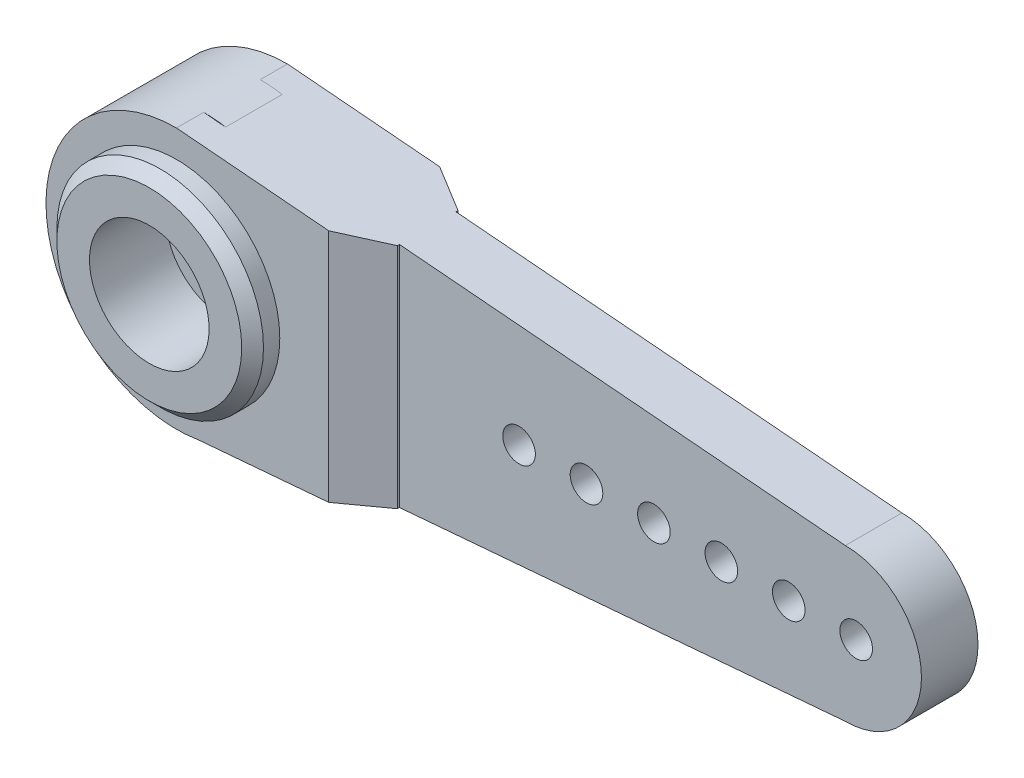
from build123d import *

# Parameters (mm, degrees)
BOSS_EXTRUDE1_DEPTH = 2.6
SKETCH2_R           = 4.75
BOSS_EXTRUDE2_DEPTH = 2.5
SKETCH3_R           = 2.5
CUT_EXTRUDE1_DEPTH  = 4
SKETCH4_R           = 0.75
CUT_EXTRUDE2_DEPTH  = 4
SKETCH5_R           = 4.75
BOSS_EXTRUDE3_DEPTH = 1.25
CHAMFER1_SIZE       = 2
CHAMFER1_SIZE2      = 1.154700538
BOSS_EXTRUDE4_DEPTH = 1.25
CHAMFER2_SIZE       = 2
CHAMFER2_SIZE2      = 1.154700538
SKETCH7_W           = 3
SKETCH7_H           = 5
CUT_EXTRUDE3_DEPTH  = 1.25
SKETCH8_R           = 2.75
CUT_EXTRUDE4_DEPTH  = 3.5
SKETCH9_R           = 3.4
CUT_EXTRUDE5_DEPTH  = 2
CHAMFER3_SIZE       = 0.5
SKETCH10_R          = 1.5
CUT_EXTRUDE6_DEPTH  = 5


with BuildPart() as part:
    # Sketch1 → Boss-Extrude1 (new body)
    with BuildSketch(Plane.XY):
        with BuildLine():
            Line((1.009697661, 5.914432402), (29.5, 3.5))
            ThreePointArc((29.5, 3.5), (33, 0), (29.5, -3.5))
            Line((29.5, -3.5), (1.009697661, -5.914432402))
            ThreePointArc((1.009697661, -5.914432402), (-6, 0), (1.009697661, 5.914432402))
        make_face()
    extrude(amount=BOSS_EXTRUDE1_DEPTH)

    # Sketch2 → Boss-Extrude2 (add)
    with BuildSketch(Plane.XY.offset(2.6)):
        Circle(SKETCH2_R)
    extrude(amount=BOSS_EXTRUDE2_DEPTH)

    # Sketch3 → Cut-Extrude1 (cut)
    with BuildSketch(Plane.XY.offset(2.6)):
        Circle(SKETCH3_R)
    extrude(amount=CUT_EXTRUDE1_DEPTH, mode=Mode.SUBTRACT)

    # Sketch4 → Cut-Extrude2 (cut)
    with BuildSketch(Plane.XY.offset(2.6)):
        with Locations((30, 0)):
            Circle(SKETCH4_R)
        with Locations((26.9, 0)):
            Circle(SKETCH4_R)
        with Locations((23.8, 0)):
            Circle(SKETCH4_R)
        with Locations((20.7, 0)):
            Circle(SKETCH4_R)
        with Locations((17.6, 0)):
            Circle(SKETCH4_R)
        with Locations((14.5, 0)):
            Circle(SKETCH4_R)
    extrude(amount=-CUT_EXTRUDE2_DEPTH, mode=Mode.SUBTRACT)

    # Sketch5 → Boss-Extrude3 (add)
    with BuildSketch(Plane.XY.offset(2.6)):
        with BuildLine():
            Line((1.009697661, 5.914432402), (0, 6))
            ThreePointArc((0, 6), (-5.978569829, -0.50665846), (1.009697661, -5.914432402))
            Line((1.009697661, -5.914432402), (9, -5.237288136))
            Line((9, -5.237288136), (9, 5.237288136))
            Line((9, 5.237288136), (1.009697661, 5.914432402))
        make_face()
        Circle(SKETCH5_R, mode=Mode.SUBTRACT)
    extrude(amount=BOSS_EXTRUDE3_DEPTH)

    # Chamfer1
    chamfer1_edges = [part.edges().sort_by_distance(p)[0] for p in [
        (9, 0, 3.85),
    ]]
    chamfer1_side = [part.faces().sort_by_distance(p)[0] for p in [
        (4.988627845, -5.384452642, 3.85),
    ]]
    chamfer(chamfer1_edges, length=CHAMFER1_SIZE, length2=CHAMFER1_SIZE2, reference=chamfer1_side[0])

    # Sketch6 → Boss-Extrude4 (add)
    with BuildSketch(Plane(origin=(0, 0, 0), x_dir=(-1, 0, 0), z_dir=(0, 0, -1))):
        with BuildLine():
            Line((-1.009697661, -5.914432402), (0, -6))
            ThreePointArc((0, -6), (6, 0), (0, 6))
            Line((0, 6), (-1.009697661, 5.914432402))
            Line((-1.009697661, 5.914432402), (-9, 5.237288136))
            Line((-9, 5.237288136), (-9, -5.237288136))
            Line((-9, -5.237288136), (-1.009697661, -5.914432402))
        make_face()
    extrude(amount=BOSS_EXTRUDE4_DEPTH)

    # Chamfer2
    chamfer2_edges = [part.edges().sort_by_distance(p)[0] for p in [
        (9, 0, -1.25),
    ]]
    chamfer2_side = [part.faces().sort_by_distance(p)[0] for p in [
        (1.907695527, 0, -1.25),
    ]]
    chamfer(chamfer2_edges, length=CHAMFER2_SIZE, length2=CHAMFER2_SIZE2, reference=chamfer2_side[0])

    # Sketch7 → Cut-Extrude3 (cut)
    with BuildSketch(Plane(origin=(0, 0, -1.25), x_dir=(-1, 0, 0), z_dir=(0, 0, -1))):
        with Locations((-7.964462138, 0)):
            Rectangle(SKETCH7_W, SKETCH7_H)
    extrude(amount=-CUT_EXTRUDE3_DEPTH, mode=Mode.SUBTRACT)

    # Sketch8 → Cut-Extrude4 (cut)
    with BuildSketch(Plane.XY.offset(5.1)):
        Circle(SKETCH8_R)
    extrude(amount=-CUT_EXTRUDE4_DEPTH, mode=Mode.SUBTRACT)

    # Sketch9 → Cut-Extrude5 (cut)
    with BuildSketch(Plane(origin=(0, 0, -1.25), x_dir=(-1, 0, 0), z_dir=(0, 0, -1))):
        Circle(SKETCH9_R)
    extrude(amount=-CUT_EXTRUDE5_DEPTH, mode=Mode.SUBTRACT)

    # Chamfer3
    chamfer3_edges = [part.edges().sort_by_distance(p)[0] for p in [
        (-4.75, 0, 5.1),
    ]]
    chamfer(chamfer3_edges, length=CHAMFER3_SIZE)

    # Sketch10 → Cut-Extrude6 (cut)
    with BuildSketch(Plane.XY.offset(1.6)):
        Circle(SKETCH10_R)
    extrude(amount=-CUT_EXTRUDE6_DEPTH, mode=Mode.SUBTRACT)


solid = part.part
